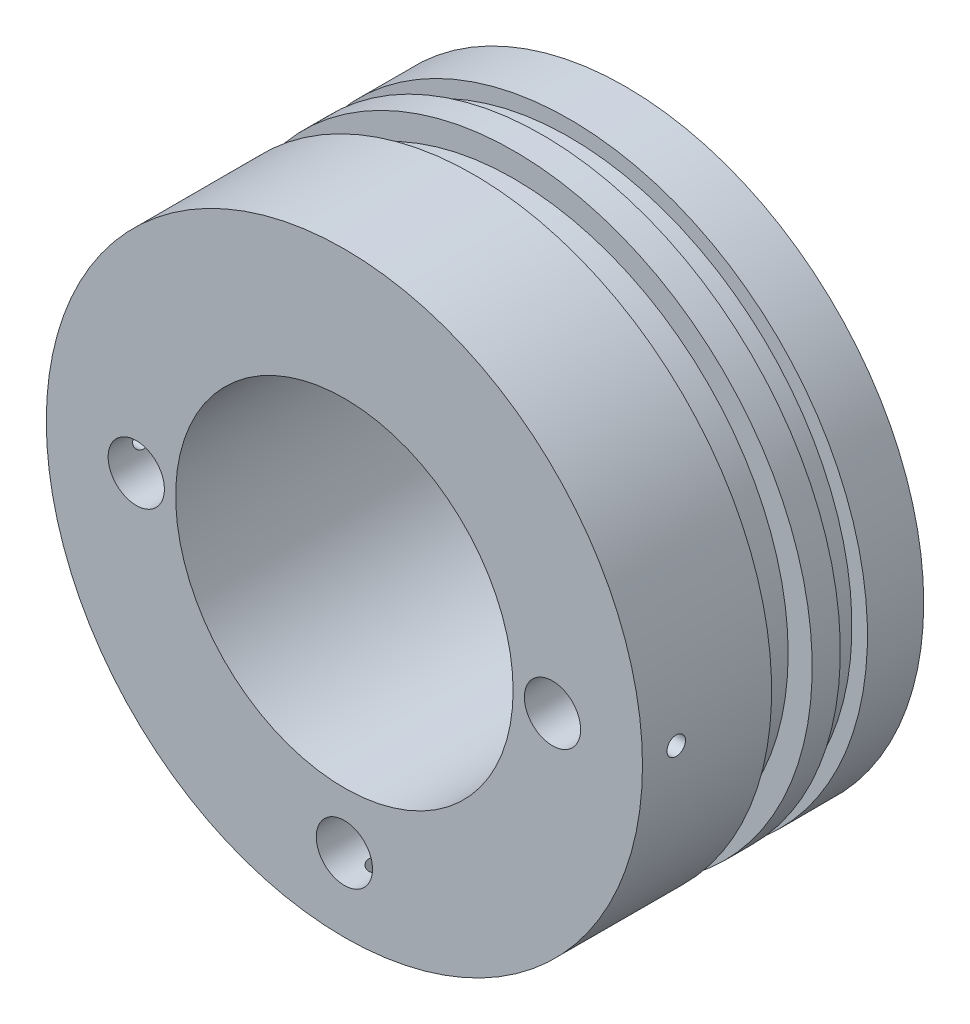
from build123d import *

# Parameters (mm, degrees)
SKETCH1_R                  = 53
BOSS_EXTRUDE1_DEPTH        = 50
F_10_0MM_DOWEL_HOLE1_D     = 10
F_10_0MM_DOWEL_HOLE1_DEPTH = 17.5
F_10_0MM_DOWEL_HOLE1_TIP   = 3.004303095
M4_TAPPED_HOLE1_REACH      = 130.627
M4_TAPPED_HOLE1_BORE_R     = 1.65
CIRPATTERN1_COUNT          = 3
CIRPATTERN1_ANGLE          = 180
SKETCH11_R                 = 30
CUT_EXTRUDE2_DEPTH         = 45
SKETCH12_W                 = 4.826
SKETCH12_H                 = 2.76515
SKETCH12_W_2               = 7.2136
SKETCH12_H_2               = 4.27264
SKETCH14_W                 = 2.667
SKETCH14_H                 = 4.572
SKETCH15_R                 = 4.5
CUT_EXTRUDE3_DEPTH         = 10
CIRPATTERN2_COUNT          = 4


with BuildPart() as part:
    # Sketch1 → Boss-Extrude1 (new body)
    with BuildSketch(Plane.XY):
        Circle(SKETCH1_R)
    extrude(amount=BOSS_EXTRUDE1_DEPTH)

    # Ø10.0mm Dowel Hole1
    with Locations(Plane.XY.offset(50)):
        with Locations((-37, 0), (37, 0), (0, -40)):
            Hole(F_10_0MM_DOWEL_HOLE1_D / 2, depth=F_10_0MM_DOWEL_HOLE1_DEPTH)
            with Locations((0, 0, -(F_10_0MM_DOWEL_HOLE1_DEPTH + F_10_0MM_DOWEL_HOLE1_TIP / 2))):  # 118° drill point
                Cone(0, F_10_0MM_DOWEL_HOLE1_D / 2, F_10_0MM_DOWEL_HOLE1_TIP, mode=Mode.SUBTRACT)

    # M4 Tapped Hole1 bore → M4 Tapped Hole1 (cut, up to next)
    with BuildSketch(Plane.ZY.offset(53), mode=Mode.PRIVATE) as m4_tapped_hole1_sk1:
        with Locations((44, 0)):
            Circle(M4_TAPPED_HOLE1_BORE_R)
    m4_tapped_hole1_tool1 = extrude(m4_tapped_hole1_sk1.sketch, amount=-M4_TAPPED_HOLE1_REACH, mode=Mode.PRIVATE) & part.part
    m4_tapped_hole1 = m4_tapped_hole1_tool1.solids().sort_by_distance((-53, 0, 44))[0]
    add(m4_tapped_hole1, mode=Mode.SUBTRACT)

    # CirPattern1: M4 Tapped Hole1 ×3 about axis
    cirpattern1_axis = Axis((0, 0, 50), (0, 0, 1))
    for i in range(1, CIRPATTERN1_COUNT):
        add(m4_tapped_hole1.rotate(cirpattern1_axis, i * CIRPATTERN1_ANGLE / (CIRPATTERN1_COUNT - 1)), mode=Mode.SUBTRACT)

    # Sketch11 → Cut-Extrude2 (cut)
    with BuildSketch(Plane.XY.offset(50)):
        Circle(SKETCH11_R)
    extrude(amount=-CUT_EXTRUDE2_DEPTH, mode=Mode.SUBTRACT)

    # Sketch12 → Cut-Revolve1 (revolve, cut)
    with BuildSketch(Plane(origin=(0, 0, 0), x_dir=(0, 0, -1), z_dir=(1, 0, 0)), mode=Mode.PRIVATE) as cut_revolve1_sk:
        with Locations((-12.413, 51.617425)):
            Rectangle(SKETCH12_W, SKETCH12_H)
        with Locations((-23.4328, 50.86368)):
            Rectangle(SKETCH12_W_2, SKETCH12_H_2)
    revolve(cut_revolve1_sk.sketch.rotate(Axis((0, 0, 0), (0, 0, 1)), 90), axis=Axis((0, 0, 0), (0, 0, 1)), mode=Mode.SUBTRACT)

    # Sketch14 → Cut-Revolve2 (revolve, cut)
    with BuildSketch(Plane(origin=(0, 0, 0), x_dir=(0, 0, -1), z_dir=(1, 0, 0)), mode=Mode.PRIVATE) as cut_revolve2_sk:
        with Locations((-1.3335, 24.8666)):
            Rectangle(SKETCH14_W, SKETCH14_H)
    revolve(cut_revolve2_sk.sketch.rotate(Axis((0, 0, 0), (0, 0, -1)), 270), axis=Axis((0, 0, 0), (0, 0, -1)), mode=Mode.SUBTRACT)

    # Sketch15 → Cut-Extrude3 (cut)
    with BuildSketch(Plane(origin=(0, 0, 0), x_dir=(-1, 0, 0), z_dir=(0, 0, -1))):
        with Locations((-10.606601718, 10.606601718)):
            Circle(SKETCH15_R)
        with Locations((0, -15)):
            Circle(SKETCH15_R)
        with Locations((10.606601718, 10.606601718)):
            Circle(SKETCH15_R)
    extrude(amount=-CUT_EXTRUDE3_DEPTH, mode=Mode.SUBTRACT)

    # Sketch17 → M5 Tapped Hole1 (revolve, cut)
    with BuildSketch(Plane(origin=(-28.284271247, 28.284271247, 0), x_dir=(0, 1, 0), z_dir=(1, 0, 0))):
        Polygon((0, 0), (0, 15.2618073), (2.1, 14), (2.1, 0), align=None)
    m5_tapped_hole1 = revolve(axis=Axis((-28.284271247, 28.284271247, -6.35), (0, 0, 1)), mode=Mode.SUBTRACT)

    # CirPattern2: M5 Tapped Hole1 ×4 about axis
    cirpattern2_axis = Axis((0, 0, 0), (0, 0, 1))
    for i in range(1, CIRPATTERN2_COUNT):
        add(m5_tapped_hole1.rotate(cirpattern2_axis, i * 360 / CIRPATTERN2_COUNT), mode=Mode.SUBTRACT)


solid = part.part
